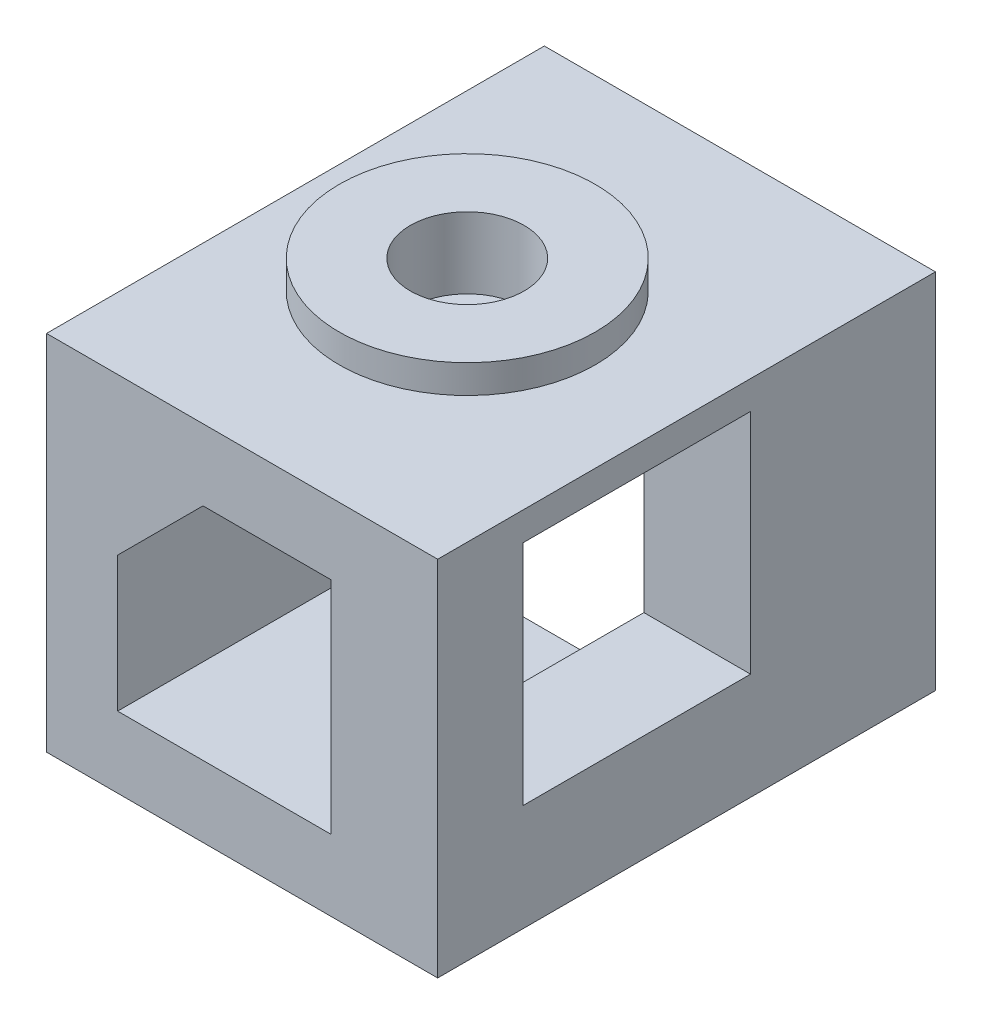
from build123d import *

# Parameters (mm, degrees)
BOSS_EXTRUDE1_DEPTH = 35
SKETCH2_R           = 9
BOSS_EXTRUDE2_DEPTH = 2
SKETCH3_R           = 4
CUT_EXTRUDE1_DEPTH  = 5
SKETCH4_W           = 7.5
SKETCH4_H           = 35
BOSS_EXTRUDE3_DEPTH = 20.5
BOSS_EXTRUDE4_START = -7.5
SKETCH6_W           = 5
SKETCH6_H           = 25.5
BOSS_EXTRUDE4_DEPTH = 7.5
SKETCH7_W           = 5
SKETCH7_H           = 20
BOSS_EXTRUDE5_DEPTH = 7.5
SKETCH8_W           = 20
SKETCH8_H           = 5
BOSS_EXTRUDE6_DEPTH = 15
SKETCH10_W          = 16
SKETCH10_H          = 16
CUT_EXTRUDE2_DEPTH  = 7.5


with BuildPart() as part:
    # Sketch1 → Boss-Extrude1 (new body)
    with BuildSketch(Plane.XY):
        Polygon((-9.305574102, 4.73561153), (18.194425898, 4.73561153), (18.194425898, -0.26438847), (1.694425898, -0.26438847), (-4.305574102, -6.26438847), (-4.305574102, -13.26438847), (-9.305574102, -13.26438847), align=None)
    extrude(amount=BOSS_EXTRUDE1_DEPTH)

    # Sketch2 → Boss-Extrude2 (add)
    with BuildSketch(Plane(origin=(0, 4.73561153, 0), x_dir=(1, 0, 0), z_dir=(0, 1, 0))):
        with Locations((2.904425898, -17.63)):
            Circle(SKETCH2_R)
    extrude(amount=BOSS_EXTRUDE2_DEPTH)

    # Sketch3 → Cut-Extrude1 (cut)
    with BuildSketch(Plane(origin=(0, 6.73561153, 0), x_dir=(1, 0, 0), z_dir=(0, 1, 0))):
        with Locations((2.904425898, -17.63)):
            Circle(SKETCH3_R)
    extrude(amount=-CUT_EXTRUDE1_DEPTH, mode=Mode.SUBTRACT)

    # Sketch4 → Boss-Extrude3 (add)
    with BuildSketch(Plane.XZ.offset(0.26438847)):
        with Locations((14.444425898, 17.5)):
            Rectangle(SKETCH4_W, SKETCH4_H)
    extrude(amount=BOSS_EXTRUDE3_DEPTH)

    # Sketch6 → Boss-Extrude4 (add)
    with BuildSketch(Plane(origin=(18.194425898, 0, 0), x_dir=(0, 0, -1), z_dir=(1, 0, 0)).offset(BOSS_EXTRUDE4_START)):
        with Locations((-2.5, -8.01438847)):
            Rectangle(SKETCH6_W, SKETCH6_H)
    extrude(amount=BOSS_EXTRUDE4_DEPTH)

    # Sketch7 → Boss-Extrude5 (add)
    with BuildSketch(Plane.XZ.offset(13.26438847)):
        with Locations((-6.805574102, 25)):
            Rectangle(SKETCH7_W, SKETCH7_H)
    extrude(amount=BOSS_EXTRUDE5_DEPTH)

    # Sketch8 → Boss-Extrude6 (add)
    with BuildSketch(Plane(origin=(-4.305574102, 0, 0), x_dir=(0, 0, -1), z_dir=(1, 0, 0))):
        with Locations((-25, -18.26438847)):
            Rectangle(SKETCH8_W, SKETCH8_H)
    extrude(amount=BOSS_EXTRUDE6_DEPTH)

    # Sketch10 → Cut-Extrude2 (cut)
    with BuildSketch(Plane(origin=(18.194425898, 0, 0), x_dir=(0, 0, -1), z_dir=(1, 0, 0))):
        with Locations((-21, -5.26438847)):
            Rectangle(SKETCH10_W, SKETCH10_H)
    extrude(amount=-CUT_EXTRUDE2_DEPTH, mode=Mode.SUBTRACT)


solid = part.part
